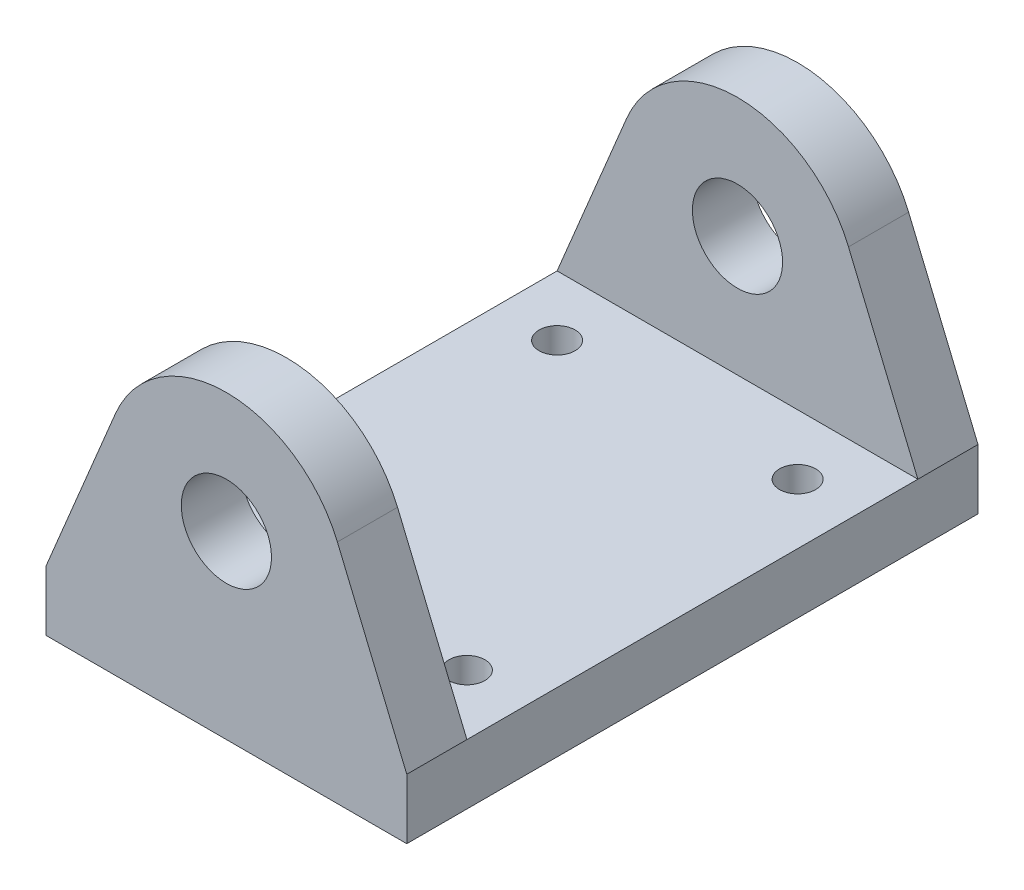
from build123d import *

# Parameters (mm, degrees)
SKETCH1_R           = 3.75
BOSS_EXTRUDE1_DEPTH = 23.75
SKETCH2_W           = 30
SKETCH2_H           = 47.5
BOSS_EXTRUDE2_DEPTH = 5
SKETCH3_W           = 37.5
SKETCH3_H           = 21.575563825
CUT_EXTRUDE1_DEPTH  = 30
SKETCH4_R           = 1.5
CUT_EXTRUDE2_DEPTH  = 5


with BuildPart() as part:
    # Sketch1 → Boss-Extrude1 (new body, symmetric)
    with BuildSketch(Plane.XY):
        with BuildLine():
            Line((-15, -10), (15, -10))
            Line((15, -10), (9.230769231, 3.846153846))
            ThreePointArc((9.230769231, 3.846153846), (0, 10), (-9.230769231, 3.846153846))
            Line((-9.230769231, 3.846153846), (-15, -10))
        make_face()
        Circle(SKETCH1_R, mode=Mode.SUBTRACT)
    extrude(amount=BOSS_EXTRUDE1_DEPTH, both=True)

    # Sketch2 → Boss-Extrude2 (add)
    with BuildSketch(Plane.XZ.offset(10)):
        Rectangle(SKETCH2_W, SKETCH2_H)
    extrude(amount=BOSS_EXTRUDE2_DEPTH)

    # Sketch3 → Cut-Extrude1 (cut)
    with BuildSketch(Plane(origin=(15, 0, 0), x_dir=(0, 0, -1), z_dir=(1, 0, 0))):
        with Locations((0, 0.787781913)):
            Rectangle(SKETCH3_W, SKETCH3_H)
    extrude(amount=-CUT_EXTRUDE1_DEPTH, mode=Mode.SUBTRACT)

    # Sketch4 → Cut-Extrude2 (cut)
    with BuildSketch(Plane(origin=(0, -10, 0), x_dir=(1, 0, 0), z_dir=(0, 1, 0))):
        with Locations((-10, 13.75)):
            Circle(SKETCH4_R)
        with Locations((10, -13.75)):
            Circle(SKETCH4_R)
        with Locations((-10, -13.75)):
            Circle(SKETCH4_R)
        with Locations((10, 13.75)):
            Circle(SKETCH4_R)
    extrude(amount=-CUT_EXTRUDE2_DEPTH, mode=Mode.SUBTRACT)


solid = part.part
